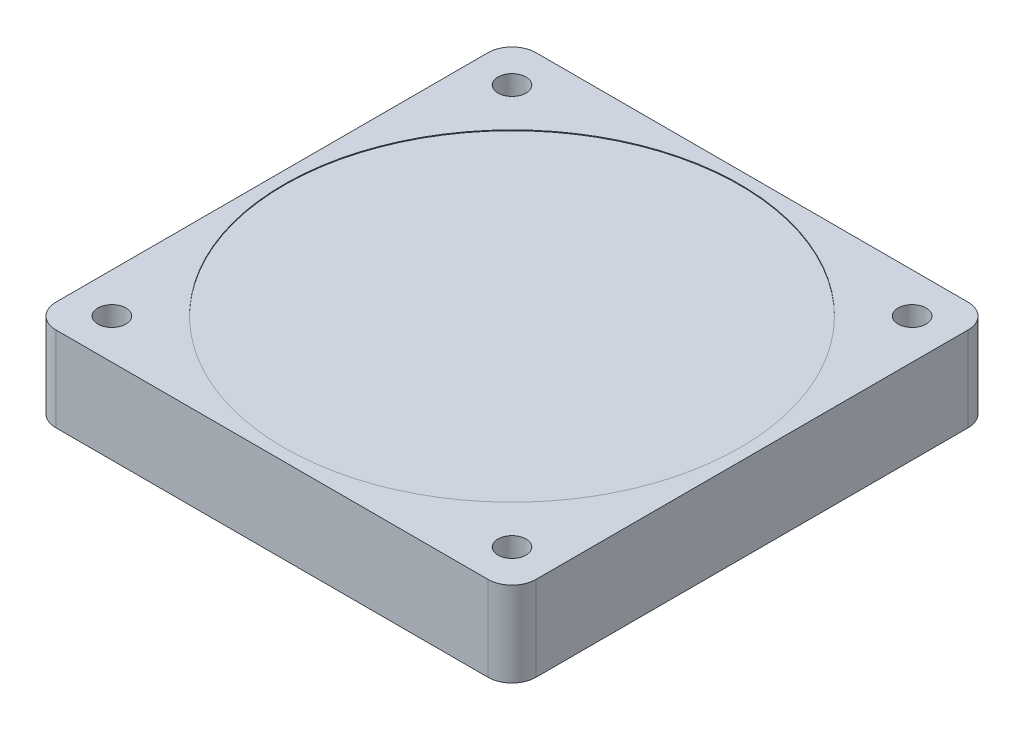
from build123d import *

# Parameters (mm, degrees)
SKETCH1_W           = 60
SKETCH1_H           = 60
BOSS_EXTRUDE1_DEPTH = 10.6
FILLET1_R           = 3
SKETCH2_R           = 1.75
CUT_EXTRUDE1_DEPTH  = 11.6
CUT_EXTRUDE2_DEPTH  = 0.1
CUT_EXTRUDE3_START  = -10.6
CUT_EXTRUDE3_DEPTH  = 0.1


with BuildPart() as part:
    # Sketch1 → Boss-Extrude1 (new body)
    with BuildSketch(Plane(origin=(0, 0, 0), x_dir=(1, 0, 0), z_dir=(0, 1, 0))):
        with Locations((6.111111111, 1.574074074)):
            Rectangle(SKETCH1_W, SKETCH1_H)
    extrude(amount=BOSS_EXTRUDE1_DEPTH)

    # Fillet1
    fillet1_edges = [part.edges().sort_by_distance(p)[0] for p in [
        (-23.888888889, 5.3, -31.574074074),
        (36.111111111, 5.3, -31.574074074),
        (36.111111111, 5.3, 28.425925926),
        (-23.888888889, 5.3, 28.425925926),
    ]]
    fillet(fillet1_edges, radius=FILLET1_R)

    # Sketch2 → Cut-Extrude1 (cut, through all)
    with BuildSketch(Plane(origin=(0, 10.6, 0), x_dir=(1, 0, 0), z_dir=(0, 1, 0))):
        with Locations((-18.888888889, 26.574074074)):
            Circle(SKETCH2_R)
        with Locations((31.111111111, 26.574074074)):
            Circle(SKETCH2_R)
        with Locations((31.111111111, -23.425925926)):
            Circle(SKETCH2_R)
        with Locations((-18.888888889, -23.425925926)):
            Circle(SKETCH2_R)
    extrude(amount=-CUT_EXTRUDE1_DEPTH, mode=Mode.SUBTRACT)

    # Sketch3 → Cut-Extrude2 (cut)
    with BuildSketch(Plane(origin=(0, 10.6, 0), x_dir=(1, 0, 0), z_dir=(0, 1, 0))):
        with BuildLine():
            ThreePointArc((34.611111111, 1.574074074), (17.017588934, 27.904640751), (-14.041432153, 21.726617338))
            Line((-14.041432153, 21.726617338), (26.263654375, -18.57846919))
            ThreePointArc((26.263654375, -18.57846919), (32.441677788, -9.332403748), (34.611111111, 1.574074074))
        make_face()
        with BuildLine():
            Line((26.263654375, -18.57846919), (-14.041432153, 21.726617338))
            ThreePointArc((-14.041432153, 21.726617338), (-14.041432153, -18.57846919), (26.263654375, -18.57846919))
        make_face()
    extrude(amount=-CUT_EXTRUDE2_DEPTH, mode=Mode.SUBTRACT)

    # Sketch3_3 → Cut-Extrude3 (cut)
    with BuildSketch(Plane(origin=(0, 10.6, 0), x_dir=(1, 0, 0), z_dir=(0, 1, 0)).offset(CUT_EXTRUDE3_START)):
        with BuildLine():
            ThreePointArc((34.611111111, 1.574074074), (17.017588934, 27.904640751), (-14.041432153, 21.726617338))
            Line((-14.041432153, 21.726617338), (26.263654375, -18.57846919))
            ThreePointArc((26.263654375, -18.57846919), (32.441677788, -9.332403748), (34.611111111, 1.574074074))
        make_face()
        with BuildLine():
            Line((26.263654375, -18.57846919), (-14.041432153, 21.726617338))
            ThreePointArc((-14.041432153, 21.726617338), (-14.041432153, -18.57846919), (26.263654375, -18.57846919))
        make_face()
    extrude(amount=CUT_EXTRUDE3_DEPTH, mode=Mode.SUBTRACT)


solid = part.part
